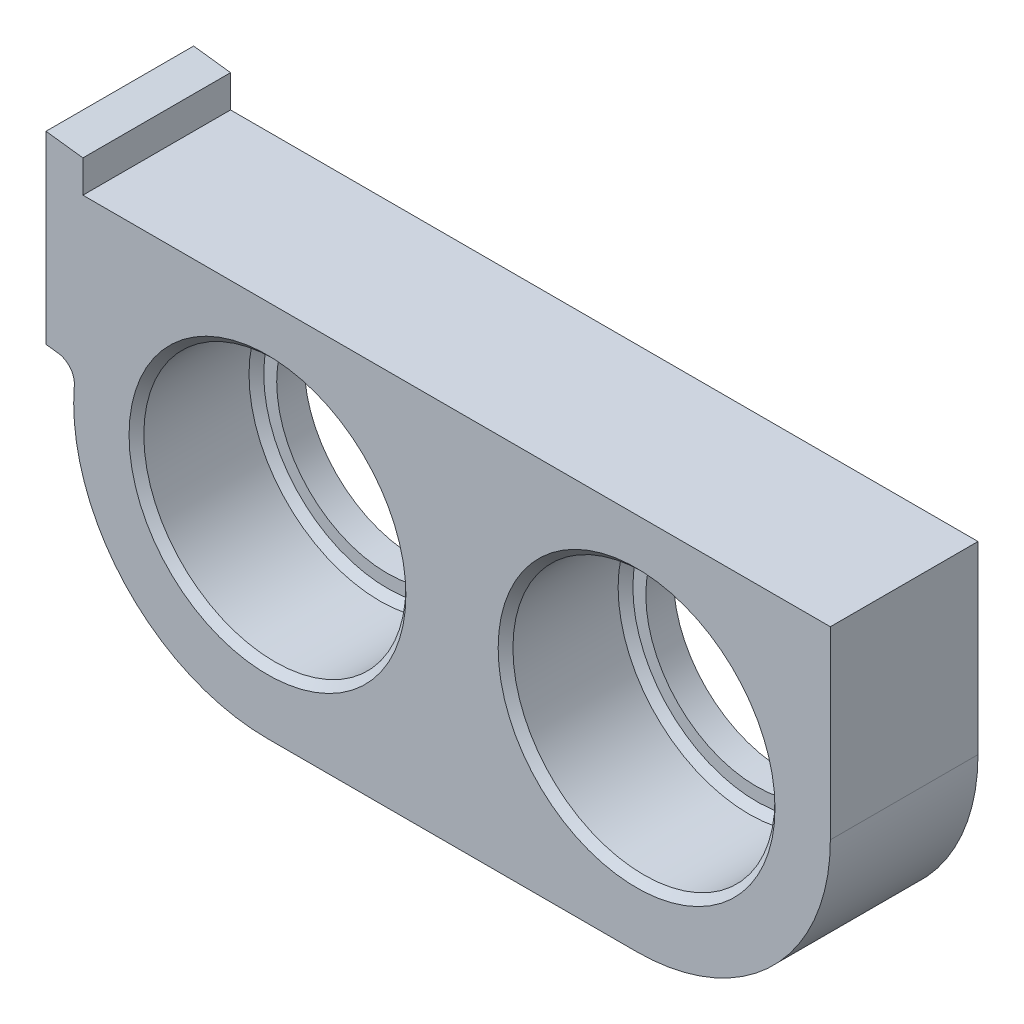
from build123d import *

# Parameters (mm, degrees)
SKETCH1_R               = 7.1
BOSS_EXTRUDE1_DEPTH     = 8
SKETCH2_R               = 7.1
SKETCH2_R_2             = 6
BOSS_EXTRUDE2_DEPTH     = 1.5
SKETCH3_W               = 10
SKETCH3_H               = 10
CUT_EXTRUDE1_DEPTH      = 31.5
CUT_EXTRUDE1_DEPTH_BACK = 10
FILLET4_R               = 1
CHAMFER1_SIZE           = 0.4


with BuildPart() as part:
    # Sketch1 → Boss-Extrude1 (new body)
    with BuildSketch(Plane.XY):
        with BuildLine():
            Line((-12, 2), (-10.345741649, 1.793217706))
            ThreePointArc((-10.345741649, 1.793217706), (-8.033641326, -6.760961991), (0, -10.5))
            Line((0, -10.5), (20, -10.5))
            ThreePointArc((20, -10.5), (27.424621202, -7.424621202), (30.5, 0))
            Line((30.5, 0), (30.5, 10.5))
            Line((30.5, 10.5), (0, 10.5))
            Line((0, 10.5), (-12, 12))
            Line((-12, 12), (-12, 2))
        make_face()
        with Locations((20, 0)):
            Circle(SKETCH1_R, mode=Mode.SUBTRACT)
        Circle(SKETCH1_R, mode=Mode.SUBTRACT)
    extrude(amount=BOSS_EXTRUDE1_DEPTH)

    # Sketch2 → Boss-Extrude2 (add)
    with BuildSketch(Plane(origin=(0, 0, 0), x_dir=(-1, 0, 0), z_dir=(0, 0, -1))):
        with Locations((-20, 0)):
            Circle(SKETCH2_R)
        with Locations((-20, 0)):
            Circle(SKETCH2_R_2, mode=Mode.SUBTRACT)
        Circle(SKETCH2_R)
        Circle(SKETCH2_R_2, mode=Mode.SUBTRACT)
    extrude(amount=-BOSS_EXTRUDE2_DEPTH)

    # Sketch3 → Cut-Extrude1 (cut, two sides)
    with BuildSketch(Plane(origin=(0, 0, 0), x_dir=(0, 0, -1), z_dir=(1, 0, 0))) as cut_extrude1_sk:
        with Locations((-4, 15)):
            Rectangle(SKETCH3_W, SKETCH3_H)
    extrude(amount=CUT_EXTRUDE1_DEPTH, mode=Mode.SUBTRACT)
    extrude(cut_extrude1_sk.sketch, amount=-CUT_EXTRUDE1_DEPTH_BACK, mode=Mode.SUBTRACT)

    # Fillet4
    fillet4_edges = [part.edges().sort_by_distance(p)[0] for p in [
        (-10.345741649, 1.793217706, 4),
    ]]
    fillet(fillet4_edges, radius=FILLET4_R)

    # Chamfer1
    chamfer1_edges = [part.edges().sort_by_distance(p)[0] for p in [
        (12.9, 0, 1.5),
        (-7.1, 0, 1.5),
        (12.9, 0, 8),
        (-7.1, 0, 8),
    ]]
    chamfer(chamfer1_edges, length=CHAMFER1_SIZE)


solid = part.part
